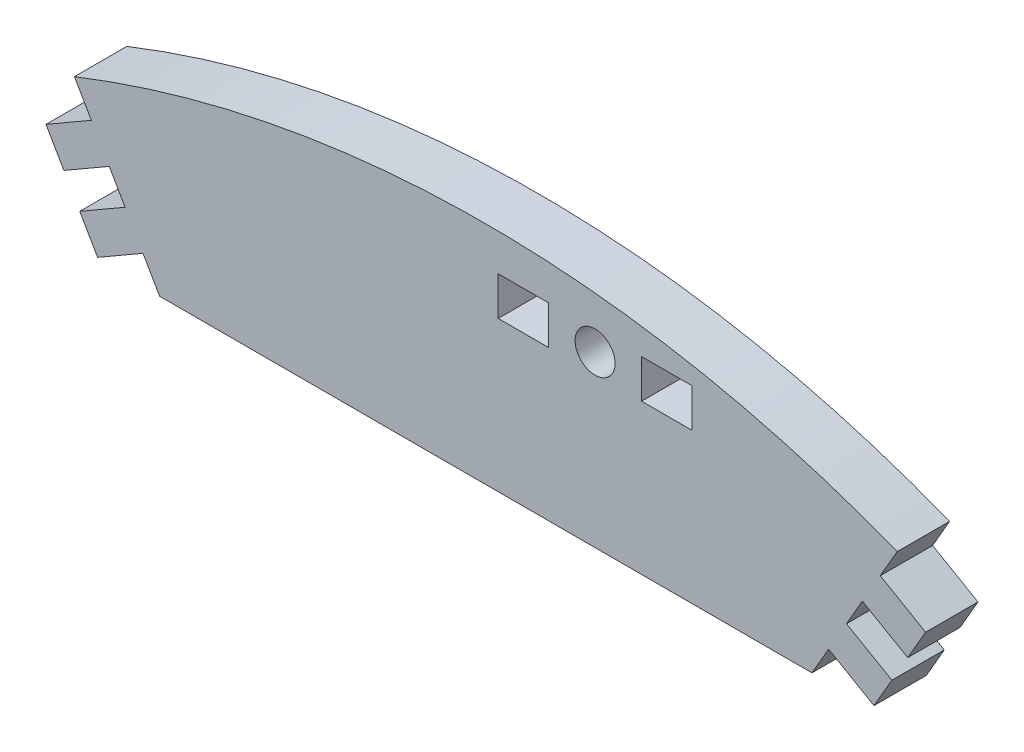
from build123d import *

# Parameters (mm, degrees)
BOSS_EXTRUDE1_DEPTH = 5.15
SKETCH2_R           = 1.9675
SKETCH2_W           = 4.95
SKETCH2_H           = 3.8
CUT_EXTRUDE1_DEPTH  = 6.15


with BuildPart() as part:
    # Sketch1 → Boss-Extrude1 (new body)
    with BuildSketch(Plane.XY):
        with BuildLine():
            Line((-32.057735027, 87.9), (32.057735027, 87.9))
            Line((32.057735027, 87.9), (33.694332379, 90.734669766))
            Line((33.694332379, 90.734669766), (38.154363209, 88.159669766))
            Line((38.154363209, 88.159669766), (39.912093048, 91.204147153))
            Line((39.912093048, 91.204147153), (35.452062218, 93.779147153))
            Line((35.452062218, 93.779147153), (37.009792057, 96.477214379))
            Line((37.009792057, 96.477214379), (41.469822887, 93.902214379))
            Line((41.469822887, 93.902214379), (43.227552726, 96.946691766))
            Line((43.227552726, 96.946691766), (38.767521896, 99.521691766))
            Line((38.767521896, 99.521691766), (40.433263841, 102.406841447))
            ThreePointArc((40.433263841, 102.406841447), (0, 110.1), (-40.433263841, 102.406841447))
            Line((-40.433263841, 102.406841447), (-38.767521896, 99.521691766))
            Line((-38.767521896, 99.521691766), (-43.227552726, 96.946691766))
            Line((-43.227552726, 96.946691766), (-41.469822887, 93.902214379))
            Line((-41.469822887, 93.902214379), (-37.009792057, 96.477214379))
            Line((-37.009792057, 96.477214379), (-35.452062218, 93.779147153))
            Line((-35.452062218, 93.779147153), (-39.912093048, 91.204147153))
            Line((-39.912093048, 91.204147153), (-38.154363209, 88.159669766))
            Line((-38.154363209, 88.159669766), (-33.694332379, 90.734669766))
            Line((-33.694332379, 90.734669766), (-32.057735027, 87.9))
        make_face()
    extrude(amount=BOSS_EXTRUDE1_DEPTH)

    # Sketch2 → Cut-Extrude1 (cut, through all)
    with BuildSketch(Plane.XY.offset(5.15)):
        with Locations((10.74, 104.550558367)):
            Circle(SKETCH2_R)
        with Locations((17.786830638, 104.550558367)):
            Rectangle(SKETCH2_W, SKETCH2_H)
        with Locations((3.693169362, 104.550558367)):
            Rectangle(SKETCH2_W, SKETCH2_H)
    extrude(amount=-CUT_EXTRUDE1_DEPTH, mode=Mode.SUBTRACT)


solid = part.part
